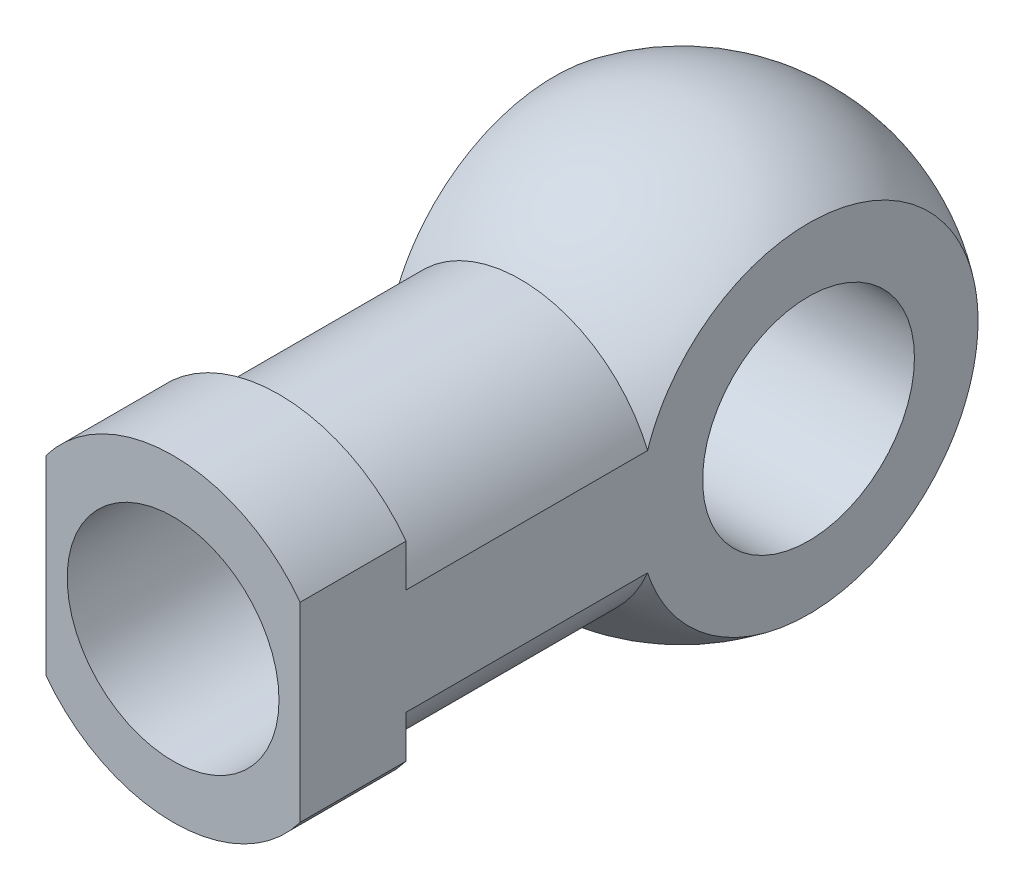
from build123d import *

# Parameters (mm, degrees)
SKETCH1_R           = 7.5
SKETCH1_R_2         = 5
BOSS_EXTRUDE1_DEPTH = 5
SKETCH2_R           = 6.5
BOSS_EXTRUDE2_DEPTH = 19
SKETCH4_W           = 21.748753338
SKETCH4_H           = 30.770097212
SKETCH4_W_2         = 12
SKETCH4_H_2         = 21.36247908
CUT_EXTRUDE1_DEPTH  = 38
SKETCH5_R           = 5
CUT_EXTRUDE2_DEPTH  = 5
SKETCH6_R           = 5
CUT_EXTRUDE3_DEPTH  = 37


with BuildPart() as part:
    # Sketch1 → Boss-Extrude1 (new body)
    with BuildSketch(Plane.XY):
        Circle(SKETCH1_R)
        Circle(SKETCH1_R_2, mode=Mode.SUBTRACT)
    extrude(amount=BOSS_EXTRUDE1_DEPTH)

    # Sketch2 → Boss-Extrude2 (add)
    with BuildSketch(Plane(origin=(0, 0, 0), x_dir=(-1, 0, 0), z_dir=(0, 0, -1))):
        Circle(SKETCH2_R)
    extrude(amount=BOSS_EXTRUDE2_DEPTH)

    # Sketch3 → Revolve9 (revolve)
    with BuildSketch(Plane(origin=(0, 0, 0), x_dir=(1, 0, 0), z_dir=(0, 1, 0))):
        with BuildLine():
            Line((0, 29), (0, 9))
            ThreePointArc((0, 9), (-10, 19), (0, 29))
        make_face()
    revolve(axis=Axis((0, 0, -29), (0, 0, 1)))

    # Sketch4 → Cut-Extrude1 (cut)
    with BuildSketch(Plane.XY.offset(5)):
        Rectangle(SKETCH4_W, SKETCH4_H)
        Rectangle(SKETCH4_W_2, SKETCH4_H_2, mode=Mode.SUBTRACT)
    extrude(amount=-CUT_EXTRUDE1_DEPTH, mode=Mode.SUBTRACT)

    # Sketch5 → Cut-Extrude2 (cut)
    with BuildSketch(Plane.XY):
        Circle(SKETCH5_R)
    extrude(amount=-CUT_EXTRUDE2_DEPTH, mode=Mode.SUBTRACT)

    # Sketch6 → Cut-Extrude3 (cut)
    with BuildSketch(Plane(origin=(6, 0, 0), x_dir=(0, 0, -1), z_dir=(1, 0, 0))):
        with Locations((19, 0)):
            Circle(SKETCH6_R)
    extrude(amount=-CUT_EXTRUDE3_DEPTH, mode=Mode.SUBTRACT)


solid = part.part
